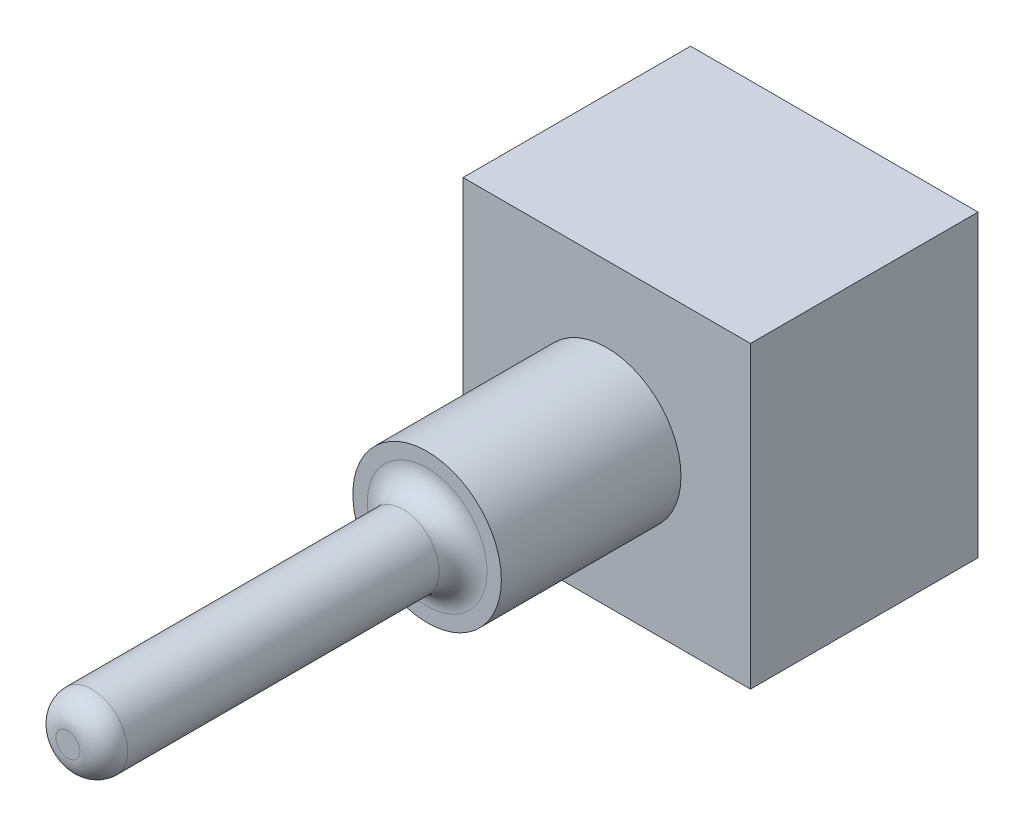
from build123d import *

# Parameters (mm, degrees)
ESQUISSE1_W        = 12
ESQUISSE1_H        = 12.5
BOSS_EXTRU_1_DEPTH = 9.5
ESQUISSE3_R        = 3.1
BOSS_EXTRU_2_DEPTH = 7.5
ESQUISSE4_R        = 1.5
BOSS_EXTRU_3_DEPTH = 15
CONG_3_R           = 1


with BuildPart() as part:
    # Esquisse1 → Boss.-Extru.1 (new body)
    with BuildSketch(Plane.XY):
        with Locations((-57.806805708, 22.931818182)):
            Rectangle(ESQUISSE1_W, ESQUISSE1_H)
    extrude(amount=BOSS_EXTRU_1_DEPTH)

    # Esquisse3 → Boss.-Extru.2 (add)
    with BuildSketch(Plane.XY.offset(9.5)):
        with Locations((-57.806805708, 22.931818182)):
            Circle(ESQUISSE3_R)
    extrude(amount=BOSS_EXTRU_2_DEPTH)

    # Esquisse4 → Boss.-Extru.3 (add)
    with BuildSketch(Plane.XY.offset(17)):
        with Locations((-57.806805708, 22.931818182)):
            Circle(ESQUISSE4_R)
    extrude(amount=BOSS_EXTRU_3_DEPTH)

    # Congé3
    cong_3_edges = [part.edges().sort_by_distance(p)[0] for p in [
        (-59.306805708, 22.931818182, 17),
        (-59.306805708, 22.931818182, 32),
    ]]
    fillet(cong_3_edges, radius=CONG_3_R)


solid = part.part
